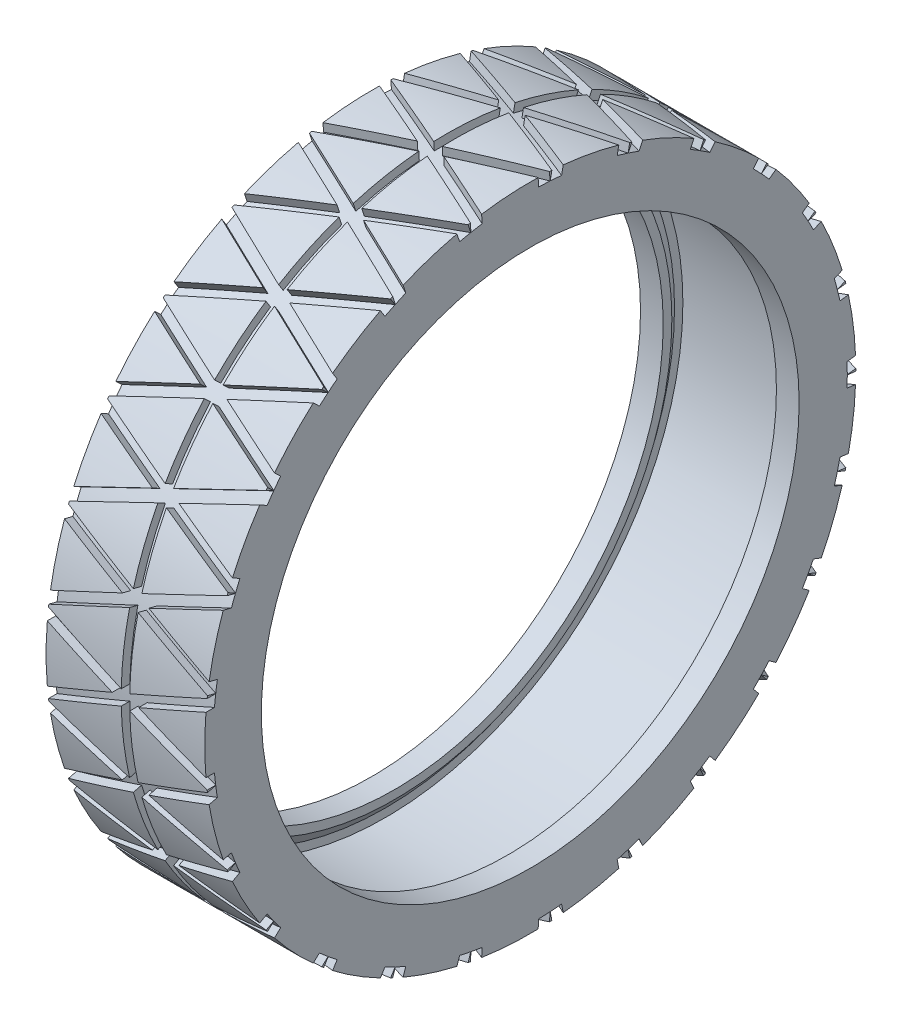
from build123d import *

# Parameters (mm, degrees)
CUT_EXTRUDE1_REACH      = 261.559
CUT_EXTRUDE1_END_RADIUS = 112
CIRPATTERN1_COUNT       = 25
SKETCH4_W               = 3
SKETCH4_H               = 3


with BuildPart() as part:
    # Sketch1 → Revolve1 (revolve)
    with BuildSketch(Plane.XY, mode=Mode.PRIVATE) as revolve1_sk:
        Polygon((0, 115), (28.02, 115), (28.02, 95), (20, 95), (20, 98.05), (23.1, 102.1), (23.1, 105.05), (0, 105.05), align=None)
    revolve1 = revolve(revolve1_sk.sketch.rotate(Axis((26.25, 0, 0), (-1, 0, 0)), 90), axis=Axis((26.25, 0, 0), (-1, 0, 0)))

    # Mirror1: Revolve1 across plane
    add(revolve1.mirror(Plane(origin=(0, 105.05, 0), x_dir=(0, 0, 1), z_dir=(-1, 0, 0))))

    # Cut-Extrude1: up to this cylinder (the profile starts outside it)
    cut_extrude1_end = Plane(origin=(0, 0, 0), z_dir=(-1, 0, 0)) * Cylinder(CUT_EXTRUDE1_END_RADIUS, 748.118, mode=Mode.PRIVATE)
    # Sketch3 → Cut-Extrude1 (cut, up to the surface)
    with BuildSketch(Plane.XY.offset(116), mode=Mode.PRIVATE) as cut_extrude1_sk1:
        Polygon((-28.02, 14), (0, 2), (28.02, 14), (28.02, 10), (4.67, 0), (28.02, -10), (28.02, -14), (0, -2), (-28.02, -14), (-28.02, -10), (-4.67, 0), (-28.02, 10), align=None)
    cut_extrude1_tool1 = extrude(cut_extrude1_sk1.sketch, amount=-CUT_EXTRUDE1_REACH, mode=Mode.PRIVATE) - cut_extrude1_end
    cut_extrude1 = cut_extrude1_tool1.solids().sort_by_distance((0, 0, 116))[0]
    add(cut_extrude1, mode=Mode.SUBTRACT)

    # CirPattern1: Cut-Extrude1 ×25 about axis
    cirpattern1_axis = Axis((0, 0, 0), (1, 0, 0))
    for i in range(1, CIRPATTERN1_COUNT):
        add(cut_extrude1.rotate(cirpattern1_axis, i * 360 / CIRPATTERN1_COUNT), mode=Mode.SUBTRACT)

    # Sketch4 → Cut-Revolve1 (revolve, cut)
    with BuildSketch(Plane.XY, mode=Mode.PRIVATE) as cut_revolve1_sk:
        with Locations((0, 113.5)):
            Rectangle(SKETCH4_W, SKETCH4_H)
    revolve(cut_revolve1_sk.sketch.rotate(Axis((26.25, 0, 0), (-1, 0, 0)), 270), axis=Axis((26.25, 0, 0), (-1, 0, 0)), mode=Mode.SUBTRACT)


solid = part.part
